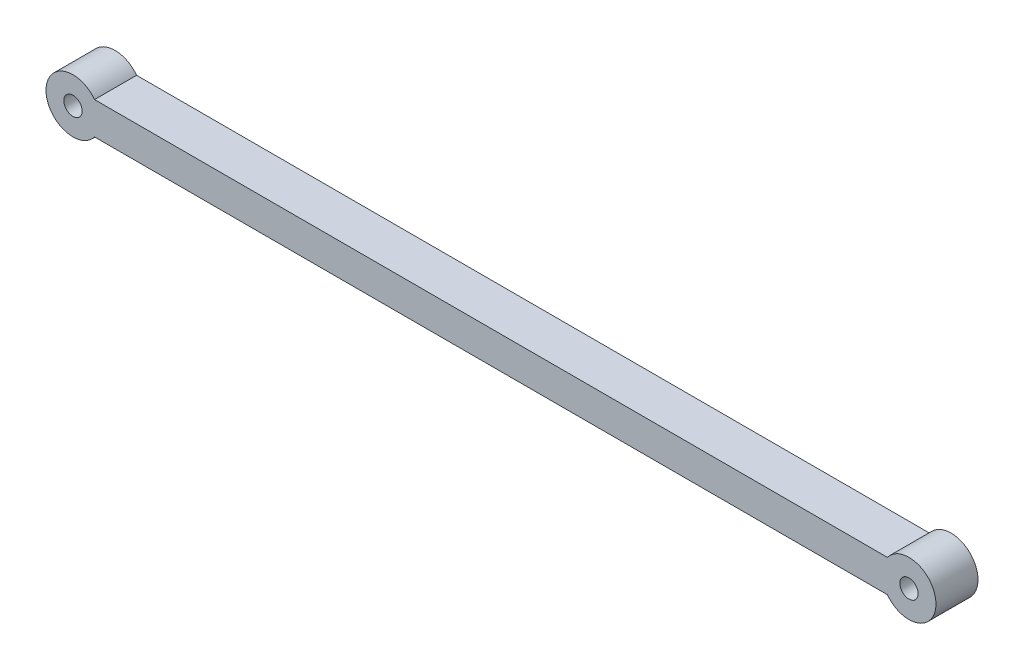
from build123d import *

# Parameters (mm, degrees)
SKETCH_1_R      = 1.7
EXTRUDE_1_DEPTH = 7.8


with BuildPart() as part:
    # 草图1 → 凸台-拉伸1 (new body)
    with BuildSketch(Plane.XY):
        with BuildLine():
            Line((4, 53), (151, 53))
            ThreePointArc((151, 53), (160, 50), (151, 47))
            Line((151, 47), (4, 47))
            ThreePointArc((4, 47), (-5, 50), (4, 53))
        make_face()
        with Locations((0, 50)):
            Circle(SKETCH_1_R, mode=Mode.SUBTRACT)
        with Locations((155, 50)):
            Circle(SKETCH_1_R, mode=Mode.SUBTRACT)
    extrude(amount=EXTRUDE_1_DEPTH)


solid = part.part
